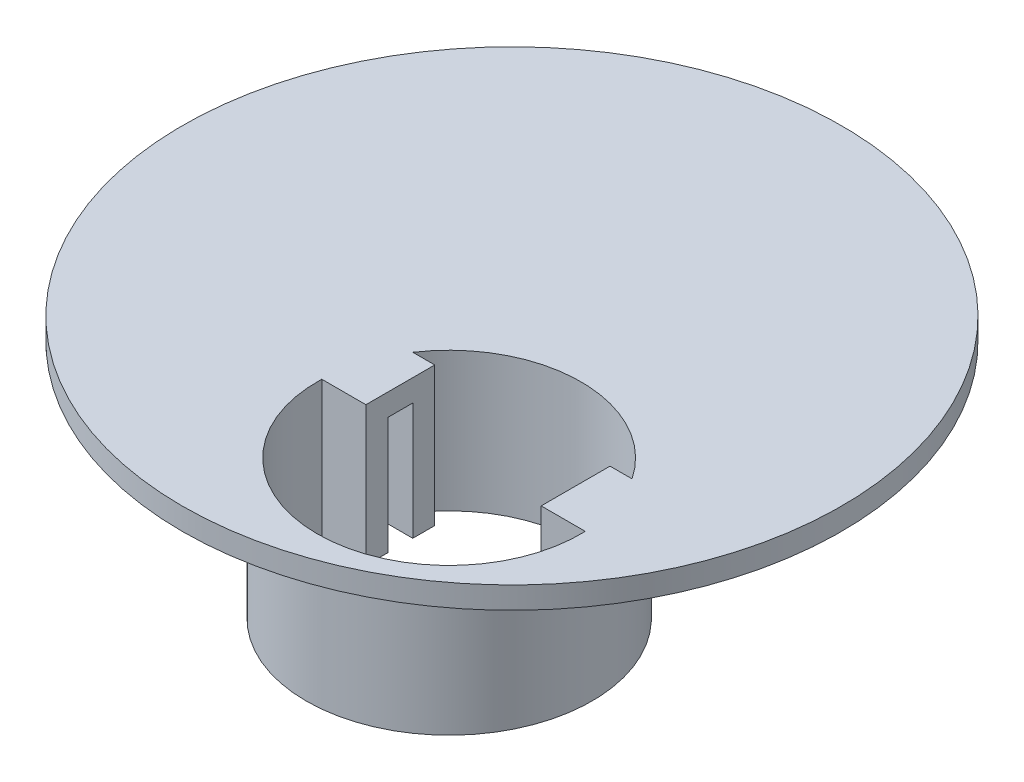
from build123d import *

# Parameters (mm, degrees)
SKETCH1_R           = 22.5
BOSS_EXTRUDE1_DEPTH = 1.5
BOSS_EXTRUDE2_START = -8
SKETCH1_3_R         = 9.761790251
SKETCH1_3_R_2       = 2.55
BOSS_EXTRUDE2_DEPTH = 8
FILLET1_R           = 1


with BuildPart() as part:
    # Sketch1 → Boss-Extrude1 (new body)
    with BuildSketch(Plane(origin=(0, 0, 0), x_dir=(1, 0, 0), z_dir=(0, 1, 0))):
        Circle(SKETCH1_R)
        with BuildLine():
            Line((0.266685226, -5.53666268), (-1.233314774, -5.53666268))
            ThreePointArc((-1.233314774, -5.53666268), (6.25, -1.53666268), (13.733314774, -5.53666268))
            Line((13.733314774, -5.53666268), (12.233314774, -5.53666268))
            Line((12.233314774, -5.53666268), (12.233314774, -10.23666268))
            Line((12.233314774, -10.23666268), (15.24499861, -10.23666268))
            ThreePointArc((15.24499861, -10.23666268), (6.25, -19.53666268), (-2.74499861, -10.23666268))
            Line((-2.74499861, -10.23666268), (0.266685226, -10.23666268))
            Line((0.266685226, -10.23666268), (0.266685226, -5.53666268))
        make_face(mode=Mode.SUBTRACT)
    extrude(amount=BOSS_EXTRUDE1_DEPTH)

    # Sketch1_3 → Boss-Extrude2 (add)
    # profile 1 of 2: a face of its own
    with BuildSketch(Plane(origin=(0, 0, 0), x_dir=(1, 0, 0), z_dir=(0, 1, 0)).offset(BOSS_EXTRUDE2_START)):
        with Locations((6.25, -10.53666268)):
            Circle(SKETCH1_3_R)
        with BuildLine():
            Line((0.266685226, -8.73666268), (-2.568163074, -8.73666268))
            ThreePointArc((-2.568163074, -8.73666268), (-2.346986264, -7.873614205), (-2.041561976, -7.03666268))
            Line((-2.041561976, -7.03666268), (0.266685226, -7.03666268))
            Line((0.266685226, -7.03666268), (0.266685226, -5.53666268))
            Line((0.266685226, -5.53666268), (-1.233314774, -5.53666268))
            ThreePointArc((-1.233314774, -5.53666268), (6.25, -1.53666268), (13.733314774, -5.53666268))
            Line((13.733314774, -5.53666268), (12.233314774, -5.53666268))
            Line((12.233314774, -5.53666268), (12.233314774, -7.03666268))
            Line((12.233314774, -7.03666268), (14.541561976, -7.03666268))
            ThreePointArc((14.541561976, -7.03666268), (14.846986264, -7.873614205), (15.068163074, -8.73666268))
            Line((15.068163074, -8.73666268), (12.233314774, -8.73666268))
            Line((12.233314774, -8.73666268), (12.233314774, -10.23666268))
            Line((12.233314774, -10.23666268), (15.24499861, -10.23666268))
            ThreePointArc((15.24499861, -10.23666268), (6.25, -19.53666268), (-2.74499861, -10.23666268))
            Line((-2.74499861, -10.23666268), (0.266685226, -10.23666268))
            Line((0.266685226, -10.23666268), (0.266685226, -8.73666268))
        make_face(mode=Mode.SUBTRACT)
    # profile 2 of 2: a face of its own
    with BuildSketch(Plane(origin=(0, 0, 0), x_dir=(1, 0, 0), z_dir=(0, 1, 0)).offset(BOSS_EXTRUDE2_START)):
        with Locations((-13.75, 8.96333732)):
            Circle(SKETCH1_3_R_2)
    extrude(amount=BOSS_EXTRUDE2_DEPTH)

    # Fillet1
    fillet1_edges = [part.edges().sort_by_distance(p)[0] for p in [
        (-16.3, -8, -8.96333732),
    ]]
    fillet(fillet1_edges, radius=FILLET1_R)


solid = part.part
